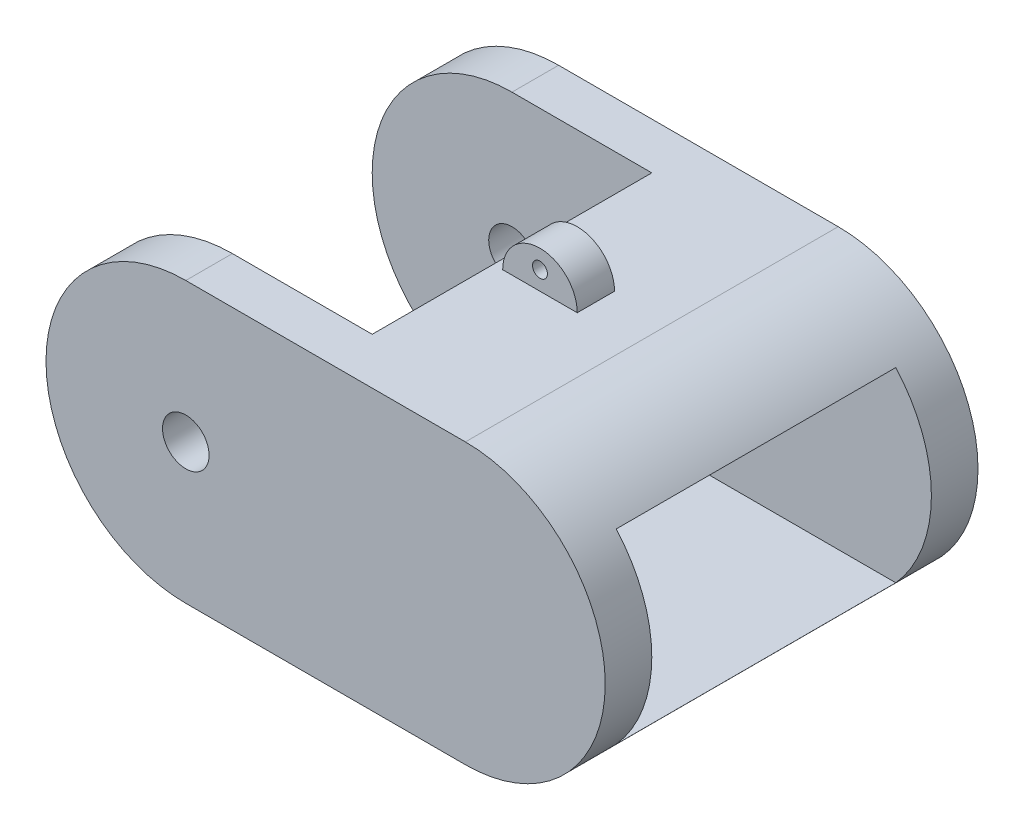
from build123d import *

# Parameters (mm, degrees)
SKETCH1_W           = 38.1
SKETCH1_H           = 25.4
BOSS_EXTRUDE1_DEPTH = 19.05
SKETCH2_R           = 1.5875
CUT_EXTRUDE2_DEPTH  = 25.4
SKETCH3_W           = 12.108446299
SKETCH3_H           = 19.05
CUT_EXTRUDE3_DEPTH  = 19.05
SKETCH4_W           = 19.05
SKETCH4_H           = 12.7
CUT_EXTRUDE4_DEPTH  = 50.8
SKETCH6_W           = 7.660570014
SKETCH6_H           = 3.81
BOSS_EXTRUDE2_DEPTH = 7.62
CUT_EXTRUDE6_DEPTH  = 19.05
SKETCH8_W           = 5.08
SKETCH8_H           = 2.54
BOSS_EXTRUDE3_DEPTH = 2.54
SKETCH9_R           = 0.508
CUT_EXTRUDE7_DEPTH  = 19.05
SKETCH10_W          = 9.525
SKETCH10_H          = 19.05
CUT_EXTRUDE8_DEPTH  = 3.81


with BuildPart() as part:
    # Sketch1 → Boss-Extrude1 (new body)
    with BuildSketch(Plane(origin=(0, 0, 0), x_dir=(1, 0, 0), z_dir=(0, 1, 0))):
        with Locations((-3.175, 0)):
            Rectangle(SKETCH1_W, SKETCH1_H)
    extrude(amount=BOSS_EXTRUDE1_DEPTH)

    # Sketch2 → Cut-Extrude2 (cut)
    with BuildSketch(Plane.XY.offset(12.7)):
        with Locations((-12.7, 9.525)):
            Circle(SKETCH2_R)
        with BuildLine():
            ThreePointArc((-12.7, 19.05), (-22.225, 9.525), (-12.7, 0))
            ThreePointArc((-12.7, 0), (-33.665146333, 9.525), (-12.7, 19.05))
        make_face()
        with BuildLine():
            ThreePointArc((6.35, 0), (15.875, 9.525), (6.35, 19.05))
            ThreePointArc((6.35, 19.05), (24.948138119, 9.525), (6.35, 0))
        make_face()
    extrude(amount=-CUT_EXTRUDE2_DEPTH, mode=Mode.SUBTRACT)

    # Sketch3 → Cut-Extrude3 (cut)
    with BuildSketch(Plane(origin=(0, 19.05, 0), x_dir=(1, 0, 0), z_dir=(0, 1, 0))):
        with Locations((-18.754223149, 0)):
            Rectangle(SKETCH3_W, SKETCH3_H)
    extrude(amount=-CUT_EXTRUDE3_DEPTH, mode=Mode.SUBTRACT)

    # Sketch4 → Cut-Extrude4 (cut)
    with BuildSketch(Plane(origin=(-15.875, 0, 0), x_dir=(0, 0, -1), z_dir=(1, 0, 0))):
        with Locations((0, 9.525)):
            Rectangle(SKETCH4_W, SKETCH4_H)
    extrude(amount=CUT_EXTRUDE4_DEPTH, mode=Mode.SUBTRACT)

    # Sketch6 → Boss-Extrude2 (add)
    with BuildSketch(Plane(origin=(0, 0, 0), x_dir=(1, 0, 0), z_dir=(0, 1, 0))):
        with Locations((-2.519714993, 0)):
            Rectangle(SKETCH6_W, SKETCH6_H)
    extrude(amount=-BOSS_EXTRUDE2_DEPTH)

    # Sketch7 → Cut-Extrude6 (cut)
    with BuildSketch(Plane.XY.offset(12.7)):
        with BuildLine():
            Line((-7.080935196, -3.131729905), (-6.858, 0))
            Line((-6.858, 0), (-6.858, -7.767816491))
            Line((-6.858, -7.767816491), (-14.771031914, -7.767816491))
            Line((-14.771031914, -7.767816491), (-14.771031914, 0))
            Line((-14.771031914, 0), (-9.975013633, 0))
            ThreePointArc((-9.975013633, 0), (-9.162678538, -1.206904896), (-8.794375076, -2.614335284))
            ThreePointArc((-8.794375076, -2.614335284), (-9.25025826, -3.647474967), (-10.163496252, -4.311706442))
            ThreePointArc((-10.163496252, -4.311706442), (-11.221462334, -3.861030674), (-11.89339597, -2.927807191))
            ThreePointArc((-11.89339597, -2.927807191), (-11.604147707, -2.390005207), (-10.996168015, -2.332941862))
            ThreePointArc((-10.996168015, -2.332941862), (-10.54556137, -1.577353268), (-11.301149964, -1.126746624))
            ThreePointArc((-11.301149964, -1.126746624), (-12.52752029, -1.573373178), (-13.044460874, -2.771802103))
            ThreePointArc((-13.044460874, -2.771802103), (-12.016160281, -5.071387383), (-9.595781192, -5.769427237))
            ThreePointArc((-9.595781192, -5.769427237), (-7.890109837, -4.877949662), (-7.080935196, -3.131729905))
        make_face()
        with BuildLine():
            Line((1.563031914, 0), (-3.232986367, 0))
            ThreePointArc((-3.232986367, 0), (-4.045321462, -1.206904896), (-4.413624924, -2.614335284))
            ThreePointArc((-4.413624924, -2.614335284), (-3.95774174, -3.647474967), (-3.044503748, -4.311706442))
            ThreePointArc((-3.044503748, -4.311706442), (-1.986537666, -3.861030674), (-1.31460403, -2.927807191))
            ThreePointArc((-1.31460403, -2.927807191), (-1.603852293, -2.390005207), (-2.211831985, -2.332941862))
            ThreePointArc((-2.211831985, -2.332941862), (-2.66243863, -1.577353268), (-1.906850036, -1.126746624))
            ThreePointArc((-1.906850036, -1.126746624), (-0.68047971, -1.573373178), (-0.163539126, -2.771802103))
            ThreePointArc((-0.163539126, -2.771802103), (-1.191839719, -5.071387383), (-3.612218808, -5.769427237))
            ThreePointArc((-3.612218808, -5.769427237), (-5.317890163, -4.877949662), (-6.127064804, -3.131729905))
            Line((-6.127064804, -3.131729905), (-6.35, 0))
            Line((-6.35, 0), (-6.35, -7.767816491))
            Line((-6.35, -7.767816491), (1.563031914, -7.767816491))
            Line((1.563031914, -7.767816491), (1.563031914, 0))
        make_face()
    extrude(amount=-CUT_EXTRUDE6_DEPTH, mode=Mode.SUBTRACT)

    # Sketch8 → Boss-Extrude3 (add)
    with BuildSketch(Plane(origin=(0, 19.05, 0), x_dir=(1, 0, 0), z_dir=(0, 1, 0))):
        Rectangle(SKETCH8_W, SKETCH8_H)
    extrude(amount=BOSS_EXTRUDE3_DEPTH)

    # Sketch9 → Cut-Extrude7 (cut)
    with BuildSketch(Plane.XY.offset(12.7)):
        with Locations((0, 20.32)):
            Circle(SKETCH9_R)
        with BuildLine():
            ThreePointArc((-2.54, 19.05), (0, 21.59), (2.54, 19.05))
            ThreePointArc((2.54, 19.05), (0, 23.383223271), (-2.54, 19.05))
        make_face()
    extrude(amount=-CUT_EXTRUDE7_DEPTH, mode=Mode.SUBTRACT)

    # Sketch10 → Cut-Extrude8 (cut)
    with BuildSketch(Plane(origin=(0, 19.05, 0), x_dir=(1, 0, 0), z_dir=(0, 1, 0))):
        with Locations((-7.9375, 0)):
            Rectangle(SKETCH10_W, SKETCH10_H)
    extrude(amount=-CUT_EXTRUDE8_DEPTH, mode=Mode.SUBTRACT)


solid = part.part
